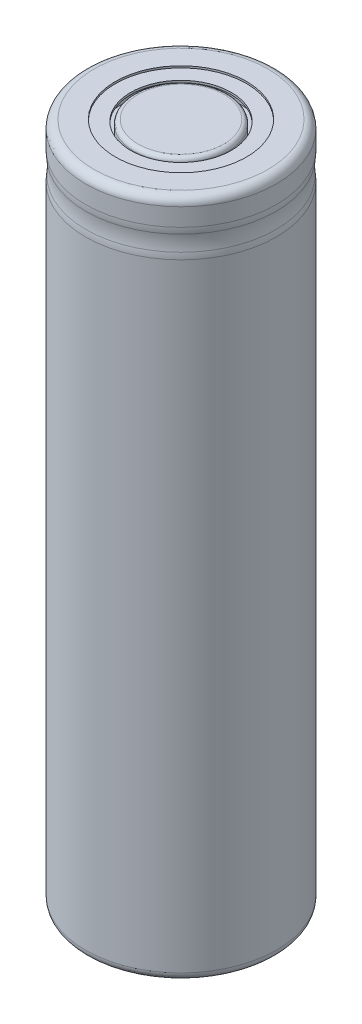
from build123d import *

# Parameters (mm, degrees)
CONG_1_R    = 0.4
CONG_2_R    = 0.8
ESQUISSE2_R = 5.05
CONG_3_R    = 4


with BuildPart() as part:
    # Esquisse1 → Révolution1 (revolve)
    with BuildSketch(Plane.XY):
        Polygon((0, 64.88), (4.5, 64.88), (4.5, 63.147633926), (5.788540515, 63.147633926), (5.788540515, 64.5), (4.8, 64.5), (4.8, 64.7), (6.25, 64.7), (6.25, 64.88), (9.1, 64.88), (9.1, 0), (7, 0), (7, 0.18), (0, 0.18), align=None)
    revolve(axis=Axis((0, 0, 0), (0, 1, 0)))

    # Congé1
    cong_1_edges = [part.edges().sort_by_distance(p)[0] for p in [
        (-4.5, 64.88, 0),
    ]]
    fillet(cong_1_edges, radius=CONG_1_R)

    # Congé2
    cong_2_edges = [part.edges().sort_by_distance(p)[0] for p in [
        (-9.1, 0, 0),
        (-9.1, 64.88, 0),
    ]]
    fillet(cong_2_edges, radius=CONG_2_R)

    # Esquisse2 → Enlèvement de matière-Révolution1 (revolve, cut)
    with BuildSketch(Plane(origin=(0, 0, 0), x_dir=(0, 0, -1), z_dir=(1, 0, 0))):
        with Locations((14.05, 61.04)):
            Circle(ESQUISSE2_R)
    revolve(axis=Axis((0, 52.453065443, 0), (0, 1, 0)), mode=Mode.SUBTRACT)

    # Congé3
    cong_3_edges = [part.edges().sort_by_distance(p)[0] for p in [
        (6.434671709, 62.04, -6.434671709),
        (-6.434671709, 60.04, 6.434671709),
    ]]
    fillet(cong_3_edges, radius=CONG_3_R)


solid = part.part
